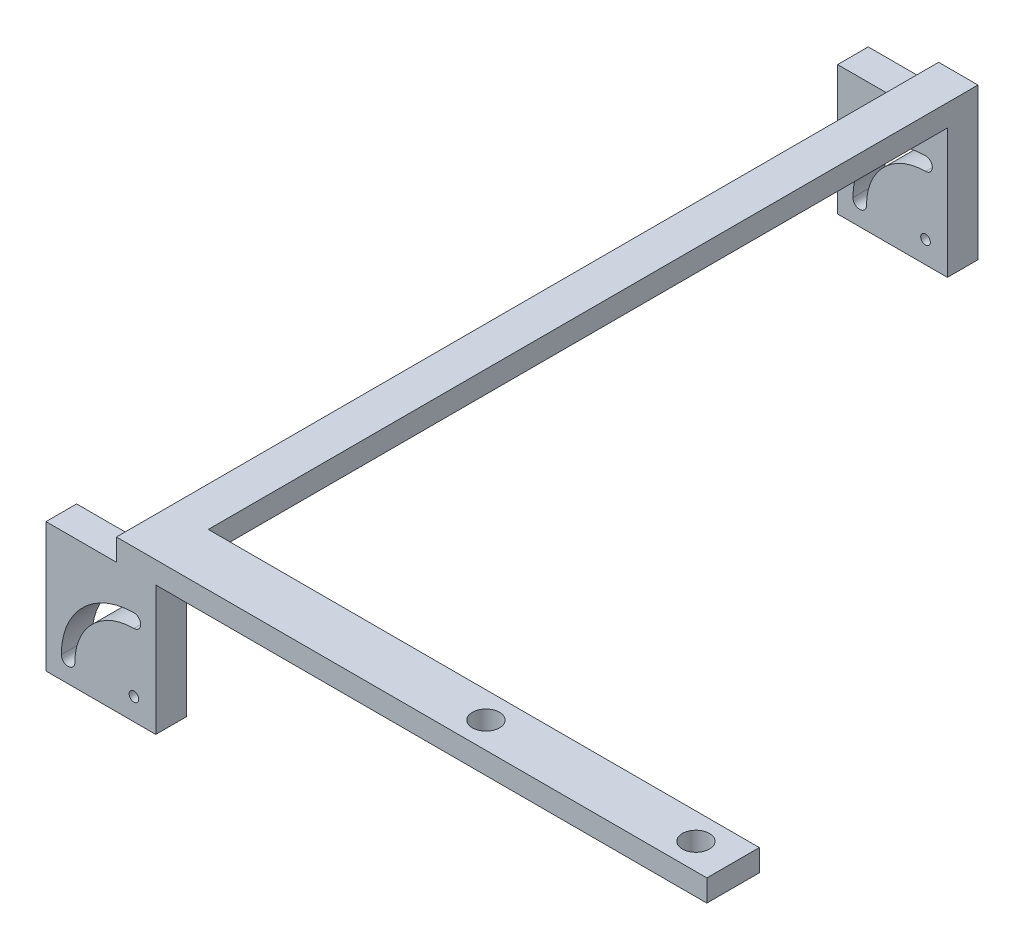
from build123d import *

# Parameters (mm, degrees)
SKETCH24_W           = 25.1
SKETCH24_H           = 29.6
BOSS_EXTRUDE8_DEPTH  = 7
SKETCH26_W           = 9
SKETCH26_H           = 7
BOSS_EXTRUDE9_DEPTH  = 5
SKETCH27_W           = 9
SKETCH27_H           = 5
BOSS_EXTRUDE10_DEPTH = 174
SKETCH28_W           = 25.1
SKETCH28_H           = 34.6
BOSS_EXTRUDE11_DEPTH = 7
SKETCH29_W           = 16.1
SKETCH29_H           = 5
CUT_EXTRUDE8_DEPTH   = 15
SKETCH32_R           = 1.1
CUT_EXTRUDE11_DEPTH  = 29
SKETCH33_R           = 1.1
CUT_EXTRUDE13_DEPTH  = 21
SKETCH35_W           = 12
SKETCH35_H           = 5
BOSS_EXTRUDE12_DEPTH = 126
SKETCH38_R           = 3.1
CUT_EXTRUDE14_DEPTH  = 126


with BuildPart() as part:
    # Sketch24 → Boss-Extrude8 (new body)
    with BuildSketch(Plane.XY):
        with Locations((12.55, 14.8)):
            Rectangle(SKETCH24_W, SKETCH24_H)
    extrude(amount=BOSS_EXTRUDE8_DEPTH)

    # Sketch26 → Boss-Extrude9 (add)
    with BuildSketch(Plane(origin=(0, 29.6, 0), x_dir=(1, 0, 0), z_dir=(0, 1, 0))):
        with Locations((20.6, -3.5)):
            Rectangle(SKETCH26_W, SKETCH26_H)
    extrude(amount=BOSS_EXTRUDE9_DEPTH)

    # Sketch27 → Boss-Extrude10 (add)
    with BuildSketch(Plane(origin=(0, 0, 0), x_dir=(-1, 0, 0), z_dir=(0, 0, -1))):
        with Locations((-20.6, 32.1)):
            Rectangle(SKETCH27_W, SKETCH27_H)
    extrude(amount=BOSS_EXTRUDE10_DEPTH)

    # Sketch28 → Boss-Extrude11 (add)
    with BuildSketch(Plane(origin=(0, 0, -174), x_dir=(-1, 0, 0), z_dir=(0, 0, -1))):
        with Locations((-12.55, 17.3)):
            Rectangle(SKETCH28_W, SKETCH28_H)
    extrude(amount=BOSS_EXTRUDE11_DEPTH)

    # Sketch29 → Cut-Extrude8 (cut)
    with BuildSketch(Plane.XY.offset(-174)):
        with Locations((8.05, 32.1)):
            Rectangle(SKETCH29_W, SKETCH29_H)
    extrude(amount=-CUT_EXTRUDE8_DEPTH, mode=Mode.SUBTRACT)

    # Sketch32 → Cut-Extrude11 (cut)
    with BuildSketch(Plane(origin=(0, 0, -181), x_dir=(-1, 0, 0), z_dir=(0, 0, -1))):
        with Locations((-20.1, 5)):
            Circle(SKETCH32_R)
        with BuildLine():
            ThreePointArc((-6.6, 5), (-10.554058454, 14.545941546), (-20.1, 18.5))
            ThreePointArc((-20.1, 18.5), (-21.65, 20.05), (-20.1, 21.6))
            ThreePointArc((-20.1, 21.6), (-8.362027432, 16.737972568), (-3.5, 5))
            ThreePointArc((-3.5, 5), (-5.05, 3.45), (-6.6, 5))
        make_face()
    extrude(amount=-CUT_EXTRUDE11_DEPTH, mode=Mode.SUBTRACT)

    # Sketch33 → Cut-Extrude13 (cut)
    with BuildSketch(Plane.XY.offset(7)):
        with Locations((20.1, 5)):
            Circle(SKETCH33_R)
        with BuildLine():
            ThreePointArc((6.6, 5), (10.554058454, 14.545941546), (20.1, 18.5))
            ThreePointArc((20.1, 18.5), (21.65, 20.05), (20.1, 21.6))
            ThreePointArc((20.1, 21.6), (8.362027432, 16.737972568), (3.5, 5))
            ThreePointArc((3.5, 5), (5.05, 3.45), (6.6, 5))
        make_face()
    extrude(amount=-CUT_EXTRUDE13_DEPTH, mode=Mode.SUBTRACT)

    # Sketch35 → Boss-Extrude12 (add)
    with BuildSketch(Plane(origin=(25.1, 0, 0), x_dir=(0, 0, -1), z_dir=(1, 0, 0))):
        with Locations((-1, 32.1)):
            Rectangle(SKETCH35_W, SKETCH35_H)
    extrude(amount=BOSS_EXTRUDE12_DEPTH)

    # Sketch38 → Cut-Extrude14 (cut)
    with BuildSketch(Plane(origin=(0, 34.6, 0), x_dir=(1, 0, 0), z_dir=(0, 1, 0))):
        with Locations((142.6, -1)):
            Circle(SKETCH38_R)
        with Locations((94.6, -1)):
            Circle(SKETCH38_R)
    extrude(amount=-CUT_EXTRUDE14_DEPTH, mode=Mode.SUBTRACT)


solid = part.part
